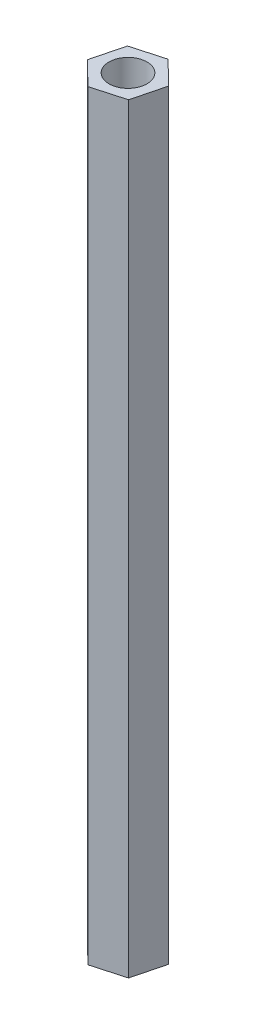
from build123d import *

# Parameters (mm, degrees)
SKETCH1_R           = 2
BOSS_EXTRUDE1_DEPTH = 80


with BuildPart() as part:
    # Sketch1 → Boss-Extrude1 (new body)
    with BuildSketch(Plane(origin=(0, 0, 0), x_dir=(1, 0, 0), z_dir=(0, 1, 0))):
        Polygon((1.930640664, -1.901825132), (2.787791347, 1.454555762), (0.309655569, 3.875060476), (-3.025630892, 2.939184295), (-3.882781574, -0.4171966), (-1.404645796, -2.837701313), align=None)
        with Locations((-0.547495114, 0.518679581)):
            Circle(SKETCH1_R, mode=Mode.SUBTRACT)
    extrude(amount=BOSS_EXTRUDE1_DEPTH)


solid = part.part
